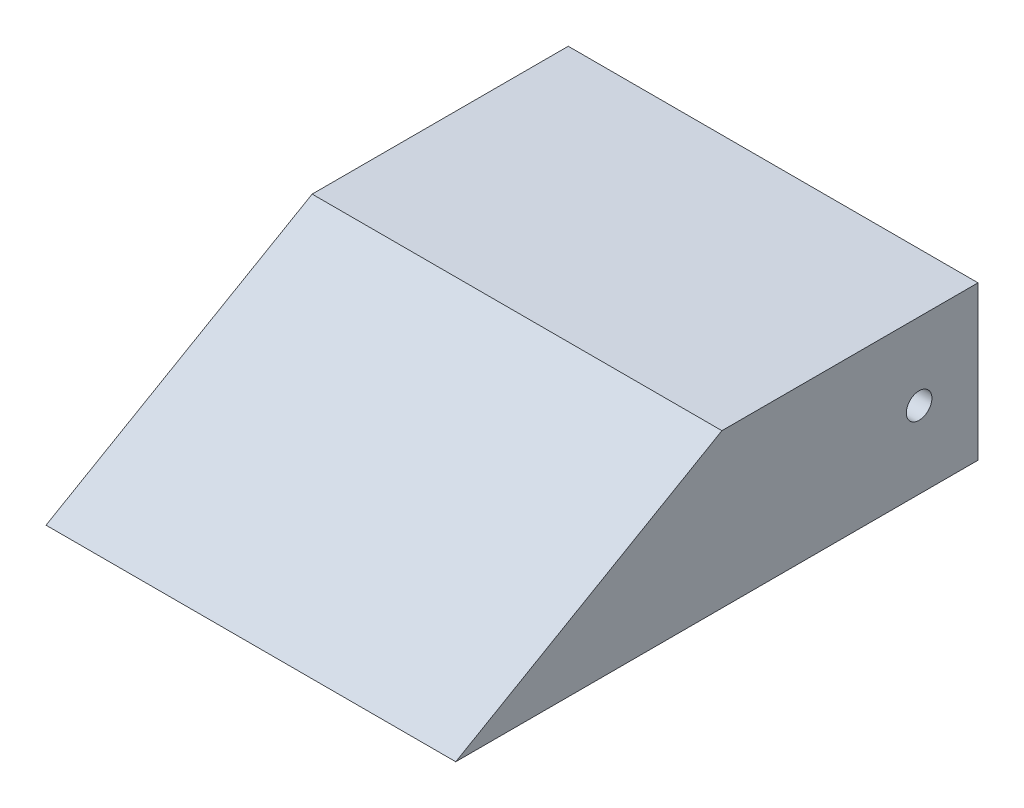
from build123d import *

# Parameters (mm, degrees)
SKETCH2_W           = 160
SKETCH2_H           = 60
BOSS_EXTRUDE1_DEPTH = 230
CUT_EXTRUDE1_REACH  = 162
SHELL1_T            = -10
SKETCH5_R           = 5
CUT_EXTRUDE2_DEPTH  = 161


with BuildPart() as part:
    # Sketch2 → Boss-Extrude1 (new body)
    with BuildSketch(Plane.XY):
        Rectangle(SKETCH2_W, SKETCH2_H)
    extrude(amount=BOSS_EXTRUDE1_DEPTH)

    # Sketch3 → Cut-Extrude1 (cut, up to next)
    with BuildSketch(Plane(origin=(80, 0, 0), x_dir=(0, 0, -1), z_dir=(1, 0, 0)), mode=Mode.PRIVATE) as cut_extrude1_sk1:
        Polygon((-100, 30), (-203.923048454, -30), (-230, -30), (-230, 30), align=None)
    cut_extrude1_tool1 = extrude(cut_extrude1_sk1.sketch, amount=-CUT_EXTRUDE1_REACH, mode=Mode.PRIVATE) & part.part
    add(cut_extrude1_tool1.solids().sort_by_distance((80, 6.658449, 185.214376))[0], mode=Mode.SUBTRACT)

    # Shell1
    shell1_openings = [part.faces().sort_by_distance(p)[0] for p in [
        (0, -30, 101.961524227),
    ]]
    offset(amount=SHELL1_T, openings=shell1_openings, kind=Kind.INTERSECTION)

    # Sketch5 → Cut-Extrude2 (cut, through all)
    with BuildSketch(Plane(origin=(80, 0, 0), x_dir=(0, 0, -1), z_dir=(1, 0, 0))):
        with Locations((-23, 0)):
            Circle(SKETCH5_R)
    extrude(amount=-CUT_EXTRUDE2_DEPTH, mode=Mode.SUBTRACT)


solid = part.part
